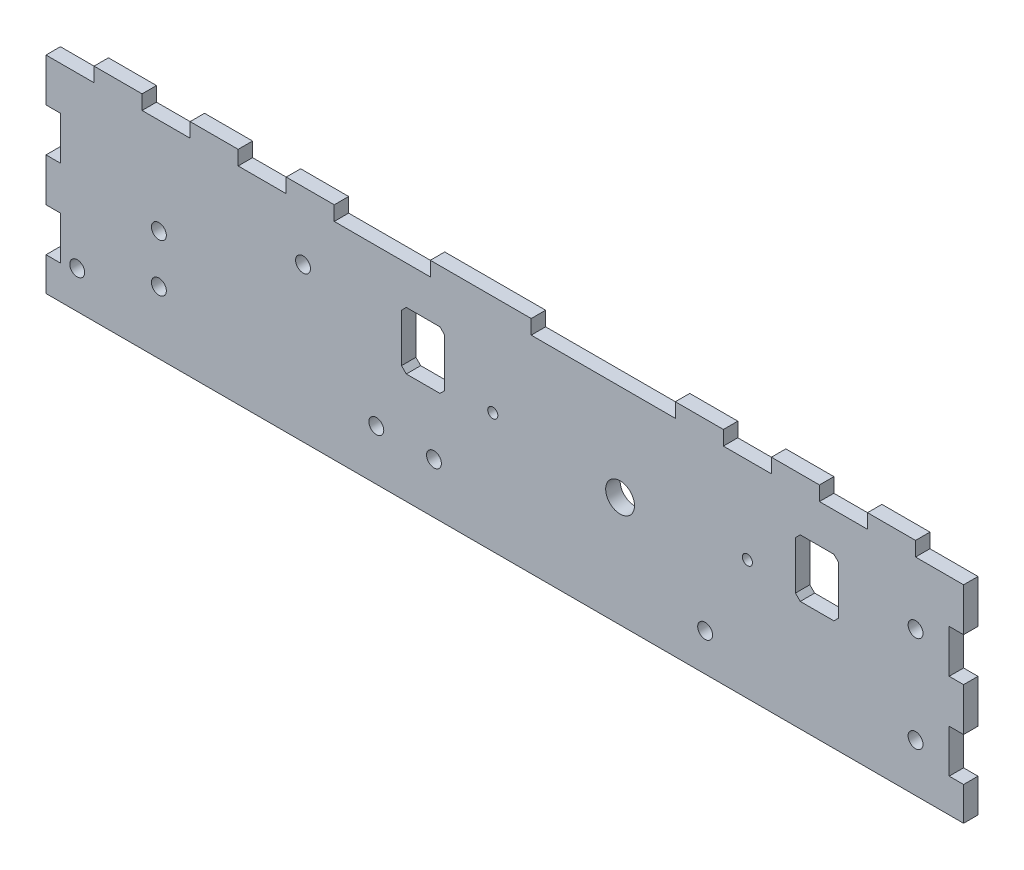
from build123d import *

# Parameters (mm, degrees)
SKETCH1_W           = 191
SKETCH1_H           = 46
SKETCH1_R           = 1.549999948
BOSS_EXTRUDE1_DEPTH = 3
CUT_EXTRUDE1_REACH  = 5
SKETCH4_W           = 10
SKETCH4_H           = 3
SKETCH4_W_2         = 20
SKETCH4_W_3         = 30
CUT_EXTRUDE2_REACH  = 5
SKETCH5_W           = 3
SKETCH5_H           = 9
CUT_EXTRUDE3_REACH  = 5
SKETCH6_W           = 3
SKETCH6_H           = 9
CUT_EXTRUDE4_REACH  = 5
SKETCH7_R           = 3
CUT_EXTRUDE5_REACH  = 5
SKETCH8_R           = 1.55
CUT_EXTRUDE6_REACH  = 5
SKETCH9_R           = 1.55
CUT_EXTRUDE7_REACH  = 5
SKETCH10_R          = 1.05
CUT_EXTRUDE8_REACH  = 5
SKETCH11_R          = 1.05


with BuildPart() as part:
    # Sketch1 → Boss-Extrude1 (new body)
    with BuildSketch(Plane.XY):
        with Locations((95.5, 23)):
            Rectangle(SKETCH1_W, SKETCH1_H)
        with Locations((181, 30)):
            Circle(SKETCH1_R, mode=Mode.SUBTRACT)
        with Locations((181, 10)):
            Circle(SKETCH1_R, mode=Mode.SUBTRACT)
    extrude(amount=BOSS_EXTRUDE1_DEPTH)

    # Sketch4 → Cut-Extrude1 (cut, up to next)
    with BuildSketch(Plane(origin=(0, 0, 0), x_dir=(-1, 0, 0), z_dir=(0, 0, -1)), mode=Mode.PRIVATE) as cut_extrude1_sk1:
        with Locations((-5, 44.5)):
            Rectangle(SKETCH4_W, SKETCH4_H)
    cut_extrude1_tool1 = extrude(cut_extrude1_sk1.sketch, amount=-CUT_EXTRUDE1_REACH, mode=Mode.PRIVATE) & part.part
    add(cut_extrude1_tool1.solids().sort_by_distance((5, 44.5, 0))[0], mode=Mode.SUBTRACT)
    # Sketch4 → Cut-Extrude1 (cut, up to next)
    with BuildSketch(Plane(origin=(0, 0, 0), x_dir=(-1, 0, 0), z_dir=(0, 0, -1)), mode=Mode.PRIVATE) as cut_extrude1_sk2:
        with Locations((-25, 44.5)):
            Rectangle(SKETCH4_W, SKETCH4_H)
    cut_extrude1_tool2 = extrude(cut_extrude1_sk2.sketch, amount=-CUT_EXTRUDE1_REACH, mode=Mode.PRIVATE) & part.part
    add(cut_extrude1_tool2.solids().sort_by_distance((25, 44.5, 0))[0], mode=Mode.SUBTRACT)
    # Sketch4 → Cut-Extrude1 (cut, up to next)
    with BuildSketch(Plane(origin=(0, 0, 0), x_dir=(-1, 0, 0), z_dir=(0, 0, -1)), mode=Mode.PRIVATE) as cut_extrude1_sk3:
        with Locations((-45, 44.5)):
            Rectangle(SKETCH4_W, SKETCH4_H)
    cut_extrude1_tool3 = extrude(cut_extrude1_sk3.sketch, amount=-CUT_EXTRUDE1_REACH, mode=Mode.PRIVATE) & part.part
    add(cut_extrude1_tool3.solids().sort_by_distance((45, 44.5, 0))[0], mode=Mode.SUBTRACT)
    # Sketch4 → Cut-Extrude1 (cut, up to next)
    with BuildSketch(Plane(origin=(0, 0, 0), x_dir=(-1, 0, 0), z_dir=(0, 0, -1)), mode=Mode.PRIVATE) as cut_extrude1_sk4:
        with Locations((-70, 44.5)):
            Rectangle(SKETCH4_W_2, SKETCH4_H)
    cut_extrude1_tool4 = extrude(cut_extrude1_sk4.sketch, amount=-CUT_EXTRUDE1_REACH, mode=Mode.PRIVATE) & part.part
    add(cut_extrude1_tool4.solids().sort_by_distance((70, 44.5, 0))[0], mode=Mode.SUBTRACT)
    # Sketch4 → Cut-Extrude1 (cut, up to next)
    with BuildSketch(Plane(origin=(0, 0, 0), x_dir=(-1, 0, 0), z_dir=(0, 0, -1)), mode=Mode.PRIVATE) as cut_extrude1_sk5:
        with Locations((-116, 44.5)):
            Rectangle(SKETCH4_W_3, SKETCH4_H)
    cut_extrude1_tool5 = extrude(cut_extrude1_sk5.sketch, amount=-CUT_EXTRUDE1_REACH, mode=Mode.PRIVATE) & part.part
    add(cut_extrude1_tool5.solids().sort_by_distance((116, 44.5, 0))[0], mode=Mode.SUBTRACT)
    # Sketch4 → Cut-Extrude1 (cut, up to next)
    with BuildSketch(Plane(origin=(0, 0, 0), x_dir=(-1, 0, 0), z_dir=(0, 0, -1)), mode=Mode.PRIVATE) as cut_extrude1_sk6:
        with Locations((-146, 44.5)):
            Rectangle(SKETCH4_W, SKETCH4_H)
    cut_extrude1_tool6 = extrude(cut_extrude1_sk6.sketch, amount=-CUT_EXTRUDE1_REACH, mode=Mode.PRIVATE) & part.part
    add(cut_extrude1_tool6.solids().sort_by_distance((146, 44.5, 0))[0], mode=Mode.SUBTRACT)
    # Sketch4 → Cut-Extrude1 (cut, up to next)
    with BuildSketch(Plane(origin=(0, 0, 0), x_dir=(-1, 0, 0), z_dir=(0, 0, -1)), mode=Mode.PRIVATE) as cut_extrude1_sk7:
        with Locations((-166, 44.5)):
            Rectangle(SKETCH4_W, SKETCH4_H)
    cut_extrude1_tool7 = extrude(cut_extrude1_sk7.sketch, amount=-CUT_EXTRUDE1_REACH, mode=Mode.PRIVATE) & part.part
    add(cut_extrude1_tool7.solids().sort_by_distance((166, 44.5, 0))[0], mode=Mode.SUBTRACT)
    # Sketch4 → Cut-Extrude1 (cut, up to next)
    with BuildSketch(Plane(origin=(0, 0, 0), x_dir=(-1, 0, 0), z_dir=(0, 0, -1)), mode=Mode.PRIVATE) as cut_extrude1_sk8:
        with Locations((-186, 44.5)):
            Rectangle(SKETCH4_W, SKETCH4_H)
    cut_extrude1_tool8 = extrude(cut_extrude1_sk8.sketch, amount=-CUT_EXTRUDE1_REACH, mode=Mode.PRIVATE) & part.part
    add(cut_extrude1_tool8.solids().sort_by_distance((186, 44.5, 0))[0], mode=Mode.SUBTRACT)

    # Sketch5 → Cut-Extrude2 (cut, up to next)
    with BuildSketch(Plane(origin=(0, 0, 0), x_dir=(-1, 0, 0), z_dir=(0, 0, -1)), mode=Mode.PRIVATE) as cut_extrude2_sk1:
        with Locations((-1.5, 29.5)):
            Rectangle(SKETCH5_W, SKETCH5_H)
    cut_extrude2_tool1 = extrude(cut_extrude2_sk1.sketch, amount=-CUT_EXTRUDE2_REACH, mode=Mode.PRIVATE) & part.part
    add(cut_extrude2_tool1.solids().sort_by_distance((1.5, 29.5, 0))[0], mode=Mode.SUBTRACT)
    # Sketch5 → Cut-Extrude2 (cut, up to next)
    with BuildSketch(Plane(origin=(0, 0, 0), x_dir=(-1, 0, 0), z_dir=(0, 0, -1)), mode=Mode.PRIVATE) as cut_extrude2_sk2:
        with Locations((-1.5, 11.5)):
            Rectangle(SKETCH5_W, SKETCH5_H)
    cut_extrude2_tool2 = extrude(cut_extrude2_sk2.sketch, amount=-CUT_EXTRUDE2_REACH, mode=Mode.PRIVATE) & part.part
    add(cut_extrude2_tool2.solids().sort_by_distance((1.5, 11.5, 0))[0], mode=Mode.SUBTRACT)

    # Sketch6 → Cut-Extrude3 (cut, up to next)
    with BuildSketch(Plane(origin=(0, 0, 0), x_dir=(-1, 0, 0), z_dir=(0, 0, -1)), mode=Mode.PRIVATE) as cut_extrude3_sk1:
        with Locations((-189.5, 29.5)):
            Rectangle(SKETCH6_W, SKETCH6_H)
    cut_extrude3_tool1 = extrude(cut_extrude3_sk1.sketch, amount=-CUT_EXTRUDE3_REACH, mode=Mode.PRIVATE) & part.part
    add(cut_extrude3_tool1.solids().sort_by_distance((189.5, 29.5, 0))[0], mode=Mode.SUBTRACT)
    # Sketch6 → Cut-Extrude3 (cut, up to next)
    with BuildSketch(Plane(origin=(0, 0, 0), x_dir=(-1, 0, 0), z_dir=(0, 0, -1)), mode=Mode.PRIVATE) as cut_extrude3_sk2:
        with Locations((-189.5, 11.5)):
            Rectangle(SKETCH6_W, SKETCH6_H)
    cut_extrude3_tool2 = extrude(cut_extrude3_sk2.sketch, amount=-CUT_EXTRUDE3_REACH, mode=Mode.PRIVATE) & part.part
    add(cut_extrude3_tool2.solids().sort_by_distance((189.5, 11.5, 0))[0], mode=Mode.SUBTRACT)

    # Sketch7 → Cut-Extrude4 (cut, up to next)
    with BuildSketch(Plane.XY.offset(3), mode=Mode.PRIVATE) as cut_extrude4_sk1:
        with Locations((119.5, 23)):
            Circle(SKETCH7_R)
    cut_extrude4_tool1 = extrude(cut_extrude4_sk1.sketch, amount=-CUT_EXTRUDE4_REACH, mode=Mode.PRIVATE) & part.part
    add(cut_extrude4_tool1.solids().sort_by_distance((119.5, 23, 3))[0], mode=Mode.SUBTRACT)

    # Sketch8 → Cut-Extrude5 (cut, up to next)
    with BuildSketch(Plane.XY.offset(3), mode=Mode.PRIVATE) as cut_extrude5_sk1:
        with Locations((23.5, 13)):
            Circle(SKETCH8_R)
    cut_extrude5_tool1 = extrude(cut_extrude5_sk1.sketch, amount=-CUT_EXTRUDE5_REACH, mode=Mode.PRIVATE) & part.part
    add(cut_extrude5_tool1.solids().sort_by_distance((23.5, 13, 3))[0], mode=Mode.SUBTRACT)
    # Sketch8 → Cut-Extrude5 (cut, up to next)
    with BuildSketch(Plane.XY.offset(3), mode=Mode.PRIVATE) as cut_extrude5_sk2:
        with Locations((23.5, 23)):
            Circle(SKETCH8_R)
    cut_extrude5_tool2 = extrude(cut_extrude5_sk2.sketch, amount=-CUT_EXTRUDE5_REACH, mode=Mode.PRIVATE) & part.part
    add(cut_extrude5_tool2.solids().sort_by_distance((23.5, 23, 3))[0], mode=Mode.SUBTRACT)
    # Sketch8 → Cut-Extrude5 (cut, up to next)
    with BuildSketch(Plane.XY.offset(3), mode=Mode.PRIVATE) as cut_extrude5_sk3:
        with Locations((53.5, 32)):
            Circle(SKETCH8_R)
    cut_extrude5_tool3 = extrude(cut_extrude5_sk3.sketch, amount=-CUT_EXTRUDE5_REACH, mode=Mode.PRIVATE) & part.part
    add(cut_extrude5_tool3.solids().sort_by_distance((53.5, 32, 3))[0], mode=Mode.SUBTRACT)
    # Sketch8 → Cut-Extrude5 (cut, up to next)
    with BuildSketch(Plane.XY.offset(3), mode=Mode.PRIVATE) as cut_extrude5_sk4:
        with Locations((68.757359313, 10.5)):
            Circle(SKETCH8_R)
    cut_extrude5_tool4 = extrude(cut_extrude5_sk4.sketch, amount=-CUT_EXTRUDE5_REACH, mode=Mode.PRIVATE) & part.part
    add(cut_extrude5_tool4.solids().sort_by_distance((68.757359, 10.5, 3))[0], mode=Mode.SUBTRACT)
    # Sketch8 → Cut-Extrude5 (cut, up to next)
    with BuildSketch(Plane.XY.offset(3), mode=Mode.PRIVATE) as cut_extrude5_sk5:
        with Locations((80.757359313, 10.5)):
            Circle(SKETCH8_R)
    cut_extrude5_tool5 = extrude(cut_extrude5_sk5.sketch, amount=-CUT_EXTRUDE5_REACH, mode=Mode.PRIVATE) & part.part
    add(cut_extrude5_tool5.solids().sort_by_distance((80.757359, 10.5, 3))[0], mode=Mode.SUBTRACT)

    # Sketch9 → Cut-Extrude6 (cut, up to next)
    with BuildSketch(Plane(origin=(0, 0, 0), x_dir=(-1, 0, 0), z_dir=(0, 0, -1)), mode=Mode.PRIVATE) as cut_extrude6_sk1:
        with Locations((-137.2, 7.8)):
            Circle(SKETCH9_R)
    cut_extrude6_tool1 = extrude(cut_extrude6_sk1.sketch, amount=-CUT_EXTRUDE6_REACH, mode=Mode.PRIVATE) & part.part
    add(cut_extrude6_tool1.solids().sort_by_distance((137.2, 7.8, 0))[0], mode=Mode.SUBTRACT)
    # Sketch9 → Cut-Extrude6 (cut, up to next)
    with BuildSketch(Plane(origin=(0, 0, 0), x_dir=(-1, 0, 0), z_dir=(0, 0, -1)), mode=Mode.PRIVATE) as cut_extrude6_sk2:
        with Locations((-6.5, 7.8)):
            Circle(SKETCH9_R)
    cut_extrude6_tool2 = extrude(cut_extrude6_sk2.sketch, amount=-CUT_EXTRUDE6_REACH, mode=Mode.PRIVATE) & part.part
    add(cut_extrude6_tool2.solids().sort_by_distance((6.5, 7.8, 0))[0], mode=Mode.SUBTRACT)

    # Sketch10 → Cut-Extrude7 (cut, up to next)
    with BuildSketch(Plane.XY.offset(3), mode=Mode.PRIVATE) as cut_extrude7_sk1:
        with Locations((93, 25)):
            Circle(SKETCH10_R)
    cut_extrude7_tool1 = extrude(cut_extrude7_sk1.sketch, amount=-CUT_EXTRUDE7_REACH, mode=Mode.PRIVATE) & part.part
    add(cut_extrude7_tool1.solids().sort_by_distance((93, 25, 3))[0], mode=Mode.SUBTRACT)
    # Sketch10 → Cut-Extrude7 (cut, up to next)
    with BuildSketch(Plane.XY.offset(3), mode=Mode.PRIVATE) as cut_extrude7_sk2:
        Polygon((83, 24), (83, 34), (82, 35), (75, 35), (74, 34), (74, 24), (75, 23), (82, 23), align=None)
    cut_extrude7_tool2 = extrude(cut_extrude7_sk2.sketch, amount=-CUT_EXTRUDE7_REACH, mode=Mode.PRIVATE) & part.part
    add(cut_extrude7_tool2.solids().sort_by_distance((78.5, 29, 3))[0], mode=Mode.SUBTRACT)

    # Sketch11 → Cut-Extrude8 (cut, up to next)
    with BuildSketch(Plane.XY.offset(3), mode=Mode.PRIVATE) as cut_extrude8_sk1:
        Polygon((164, 23), (157, 23), (156, 24), (156, 34), (157, 35), (164, 35), (165, 34), (165, 24), align=None)
    cut_extrude8_tool1 = extrude(cut_extrude8_sk1.sketch, amount=-CUT_EXTRUDE8_REACH, mode=Mode.PRIVATE) & part.part
    add(cut_extrude8_tool1.solids().sort_by_distance((160.5, 29, 3))[0], mode=Mode.SUBTRACT)
    # Sketch11 → Cut-Extrude8 (cut, up to next)
    with BuildSketch(Plane.XY.offset(3), mode=Mode.PRIVATE) as cut_extrude8_sk2:
        with Locations((146, 25)):
            Circle(SKETCH11_R)
    cut_extrude8_tool2 = extrude(cut_extrude8_sk2.sketch, amount=-CUT_EXTRUDE8_REACH, mode=Mode.PRIVATE) & part.part
    add(cut_extrude8_tool2.solids().sort_by_distance((146, 25, 3))[0], mode=Mode.SUBTRACT)


solid = part.part
